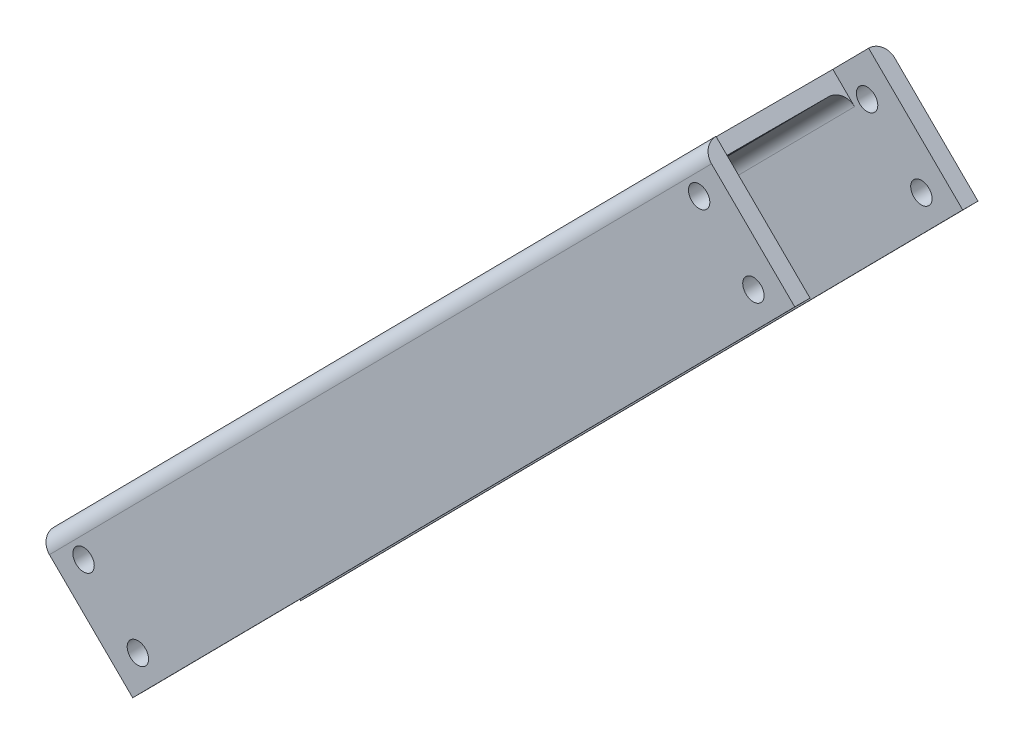
from build123d import *

# Parameters (mm, degrees)
BOSS_EXTRUDE1_DEPTH = 3
BOSS_EXTRUDE2_DEPTH = 3
BOSS_EXTRUDE3_DEPTH = 30
FILLET1_R           = 3
CUT_EXTRUDE1_REACH  = 120.494
SKETCH6_R           = 7.5
CUT_EXTRUDE2_REACH  = 120.494
SKETCH7_W           = 30
SKETCH7_H           = 10
CUT_EXTRUDE3_START  = -36
SKETCH8_R           = 2.1
CUT_EXTRUDE3_DEPTH  = 36
FILLET2_R           = 1


with BuildPart() as part:
    # Sketch2 → Boss-Extrude1 (new body)
    with BuildSketch(Plane.XY):
        Polygon((165.715003736, 148.457007378), (35.636413421, 16.910208322), (54.124071667, -1.371107074), (184.202661981, 130.175691982), align=None)
    extrude(amount=-BOSS_EXTRUDE1_DEPTH)



with BuildPart() as body_2:
    # Sketch4 → Boss-Extrude2 (new body)
    with BuildSketch(Plane(origin=(0, 0, -36), x_dir=(-1, 0, 0), z_dir=(0, 0, -1))):
        Polygon((-165.715003736, 148.457007378), (-184.202661981, 130.175691982), (-54.124071667, -1.371107074), (-35.636413421, 16.910208322), align=None)
    extrude(amount=-BOSS_EXTRUDE2_DEPTH)


with BuildPart() as part_1:
    add(part.part)

    add(body_2.part)  # Boss-Extrude3 merges body 2
    # Sketch5 → Boss-Extrude3 (add)
    with BuildSketch(Plane(origin=(0, 0, -3), x_dir=(-1, 0, 0), z_dir=(0, 0, -1))):
        Polygon((-35.636413421, 16.910208322), (-165.715003736, 148.457007378), (-167.848195072, 146.347624832), (-37.769604757, 14.800825776), align=None)
    extrude(amount=BOSS_EXTRUDE3_DEPTH)

    # Fillet1
    fillet1_edges = [part_1.edges().sort_by_distance(p)[0] for p in [
        (100.675708579, 82.68360785, -36),
        (102.808899915, 80.574225304, -33),
        (102.808899915, 80.574225304, -3),
        (100.675708579, 82.68360785, 0),
    ]]
    fillet(fillet1_edges, radius=FILLET1_R)

    # Sketch6 → Cut-Extrude1 (cut, up to next)
    with BuildSketch(Plane(origin=(9.563615855, -9.456875254, 0), x_dir=(0, 0, 1), z_dir=(-0.711063779, 0.703127515, 0)), mode=Mode.PRIVATE) as cut_extrude1_sk1:
        with Locations((-18, 197.081179448)):
            Circle(SKETCH6_R)
    cut_extrude1_tool1 = extrude(cut_extrude1_sk1.sketch, amount=-CUT_EXTRUDE1_REACH, mode=Mode.PRIVATE) & part_1.part
    add(cut_extrude1_tool1.solids().sort_by_distance((148.136816, 130.680413, -18))[0], mode=Mode.SUBTRACT)

    # Sketch7 → Cut-Extrude2 (cut, up to next)
    with BuildSketch(Plane(origin=(9.563615855, -9.456875254, 0), x_dir=(0, 0, 1), z_dir=(-0.711063779, 0.703127515, 0)), mode=Mode.PRIVATE) as cut_extrude2_sk1:
        with Locations((-18, 217.081179448)):
            Rectangle(SKETCH7_W, SKETCH7_H)
    cut_extrude2_tool1 = extrude(cut_extrude2_sk1.sketch, amount=-CUT_EXTRUDE2_REACH, mode=Mode.PRIVATE) & part_1.part
    add(cut_extrude2_tool1.solids().sort_by_distance((162.199366, 144.901688, -18))[0], mode=Mode.SUBTRACT)
    # Sketch7 → Cut-Extrude2 (cut, up to next)
    with BuildSketch(Plane(origin=(9.563615855, -9.456875254, 0), x_dir=(0, 0, 1), z_dir=(-0.711063779, 0.703127515, 0)), mode=Mode.PRIVATE) as cut_extrude2_sk2:
        with Locations((-18, 42.081179448)):
            Rectangle(SKETCH7_W, SKETCH7_H)
    cut_extrude2_tool2 = extrude(cut_extrude2_sk2.sketch, amount=-CUT_EXTRUDE2_REACH, mode=Mode.PRIVATE) & part_1.part
    add(cut_extrude2_tool2.solids().sort_by_distance((39.152051, 20.465527, -18))[0], mode=Mode.SUBTRACT)

    # Sketch8 → Cut-Extrude3 (cut)
    with BuildSketch(Plane.XY.offset(CUT_EXTRUDE3_START)):
        with Locations((176.077014239, 129.069414997)):
            Circle(SKETCH8_R)
        with Locations((165.411057559, 139.616327725)):
            Circle(SKETCH8_R)
        with Locations((44.473124942, 17.313357792)):
            Circle(SKETCH8_R)
        with Locations((55.139081623, 6.766445064)):
            Circle(SKETCH8_R)
    extrude(amount=CUT_EXTRUDE3_DEPTH, mode=Mode.SUBTRACT)

    # Fillet2
    fillet2_edges = [part_1.edges().sort_by_distance(p)[0] for p in [
        (148.136815855, 130.680412911, -25.5),
        (150.270007192, 128.571030365, -25.5),
    ]]
    fillet(fillet2_edges, radius=FILLET2_R)


solid = part_1.part
